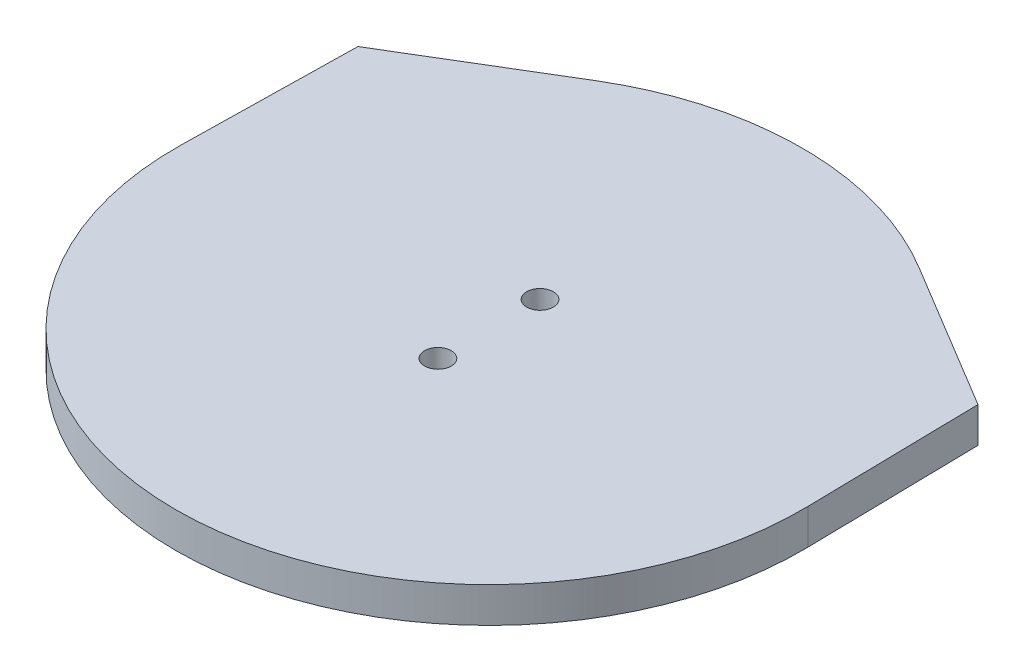
from build123d import *

# Parameters (mm, degrees)
BOSS_EXTRUDE4_DEPTH                             = 4.5
CSK_FOR_M3_FLAT_HEAD_MACHINE_SCREW1_D           = 3.4
CSK_FOR_M3_FLAT_HEAD_MACHINE_SCREW1_CSINK_D     = 6.3
CSK_FOR_M3_FLAT_HEAD_MACHINE_SCREW1_CSINK_ANGLE = 90


with BuildPart() as part:
    # Sketch6 → Boss-Extrude4 (new body)
    with BuildSketch(Plane(origin=(0, 0, 0), x_dir=(1, 0, 0), z_dir=(0, 1, 0))):
        with BuildLine():
            Line((-37.735031535, 17.5893733), (-18.832983626, 28.967073503))
            ThreePointArc((-18.832983626, 28.967073503), (1.730983294, 34.678659015), (22.294950215, 28.967073503))
            Line((22.294950215, 28.967073503), (41.196998124, 17.5893733))
            Line((41.196998124, 17.5893733), (41.599351581, -4.469130473))
            ThreePointArc((41.599351581, -4.469130473), (1.730983294, -45.071340985), (-38.137384993, -4.469130473))
            Line((-38.137384993, -4.469130473), (-37.735031535, 17.5893733))
        make_face()
    extrude(amount=BOSS_EXTRUDE4_DEPTH)

    # CSK for M3 Flat Head Machine Screw1 (through all)
    with Locations(Plane(origin=(0, 0, 5.6), x_dir=(1, 0, 0), z_dir=(0, -1, 0))):
        with Locations((1.730983294, -6.903659015), (1.730983294, 6.096340985)):
            CounterSinkHole(CSK_FOR_M3_FLAT_HEAD_MACHINE_SCREW1_D / 2, CSK_FOR_M3_FLAT_HEAD_MACHINE_SCREW1_CSINK_D / 2, counter_sink_angle=CSK_FOR_M3_FLAT_HEAD_MACHINE_SCREW1_CSINK_ANGLE)


solid = part.part
